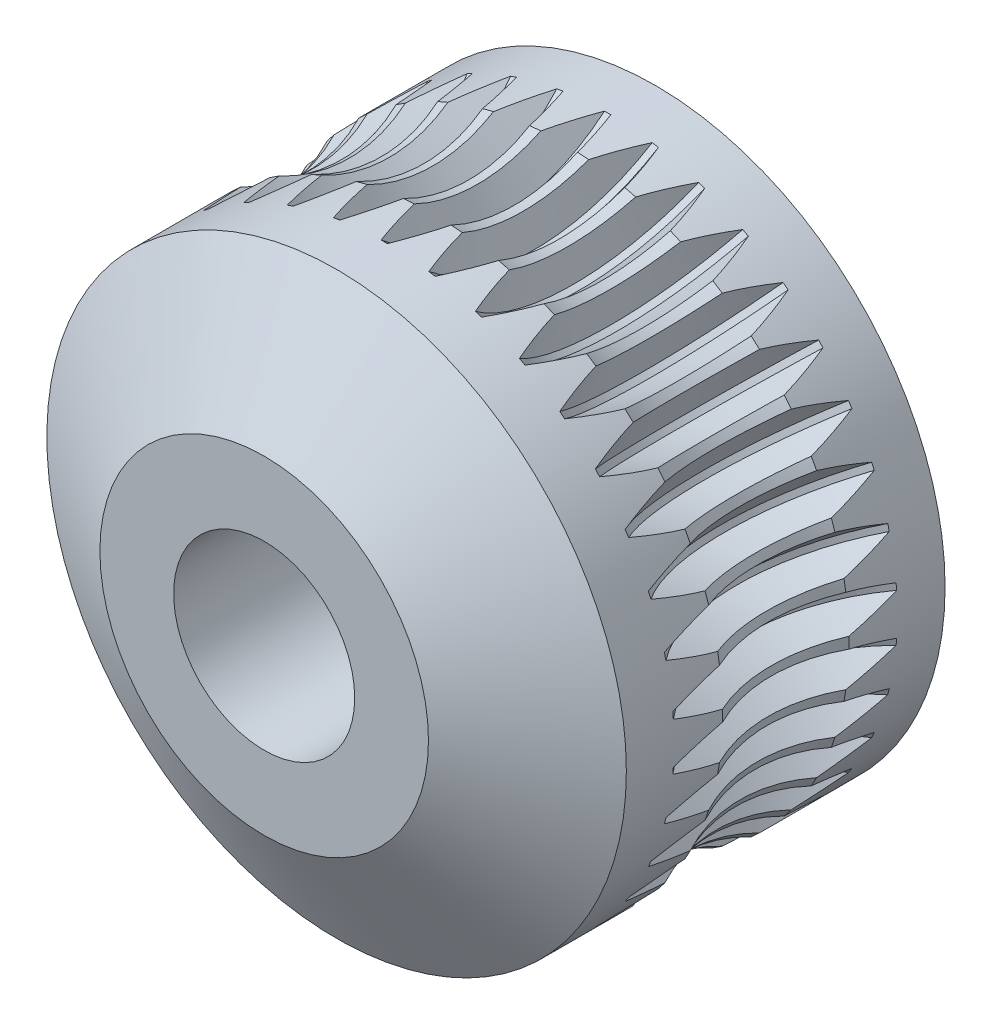
from build123d import *

# Parameters (mm, degrees)
SKETCH1_R           = 4
SKETCH1_R_2         = 1.25
BOSS_EXTRUDE1_DEPTH = 6.4
CHAMFER1_SIZE       = 1
CHAMFER1_SIZE2      = 1.732050808
SKETCH2_R           = 2
CIRPATTERN1_COUNT   = 38
CHAMFER2_SIZE       = 1
CHAMFER2_SIZE2      = 1.732050808


with BuildPart() as part:
    # Sketch1 → Boss-Extrude1 (new body)
    with BuildSketch(Plane.XY):
        Circle(SKETCH1_R)
        Circle(SKETCH1_R_2, mode=Mode.SUBTRACT)
    extrude(amount=BOSS_EXTRUDE1_DEPTH)

    # Chamfer1
    chamfer1_edges = [part.edges().sort_by_distance(p)[0] for p in [
        (-4, 0, 6.4),
    ]]
    chamfer1_side = [part.faces().sort_by_distance(p)[0] for p in [
        (-4, 0, 3.2),
    ]]
    chamfer(chamfer1_edges, length=CHAMFER1_SIZE, length2=CHAMFER1_SIZE2, reference=chamfer1_side[0])

    # Sketch2 → Cut-Revolve1 (revolve, cut)
    with BuildSketch(Plane(origin=(0, 0, 0), x_dir=(0, 0, -1), z_dir=(1, 0, 0))):
        with Locations((-3.2, 5.8)):
            Circle(SKETCH2_R)
    revolve(axis=Axis((0, 0, 0), (0, 0, 1)), mode=Mode.SUBTRACT)

    # Sketch3 → Cut-Revolve2 (revolve, cut)
    with BuildSketch(Plane(origin=(3.2, 0, 3.2), x_dir=(1, 0, 0), z_dir=(0, 0, 1))):
        Polygon((-3.24375, 3.43), (-3.15625, 3.43), (-2.9426304, 3.8), (-2.151071718, 3.8), (-2.151071718, 4.39756734), (-4.248928282, 4.39756734), (-4.248928282, 3.8), (-3.4573696, 3.8), align=None)
    cut_revolve2 = revolve(axis=Axis((-1.842545421, 5.8, 3.2), (1, 0, 0)), mode=Mode.SUBTRACT)

    # CirPattern1: Cut-Revolve2 ×38 about axis
    cirpattern1_axis = Axis((0, 0, 6.4), (0, 0, -1))
    for i in range(1, CIRPATTERN1_COUNT):
        add(cut_revolve2.rotate(cirpattern1_axis, i * 360 / CIRPATTERN1_COUNT), mode=Mode.SUBTRACT)

    # Chamfer2
    chamfer2_edges = [part.edges().sort_by_distance(p)[0] for p in [
        (-4, 0, 0),
    ]]
    chamfer2_side = [part.faces().sort_by_distance(p)[0] for p in [
        (-4, 0, 1.164110106),
    ]]
    chamfer(chamfer2_edges, length=CHAMFER2_SIZE, length2=CHAMFER2_SIZE2, reference=chamfer2_side[0])


solid = part.part
